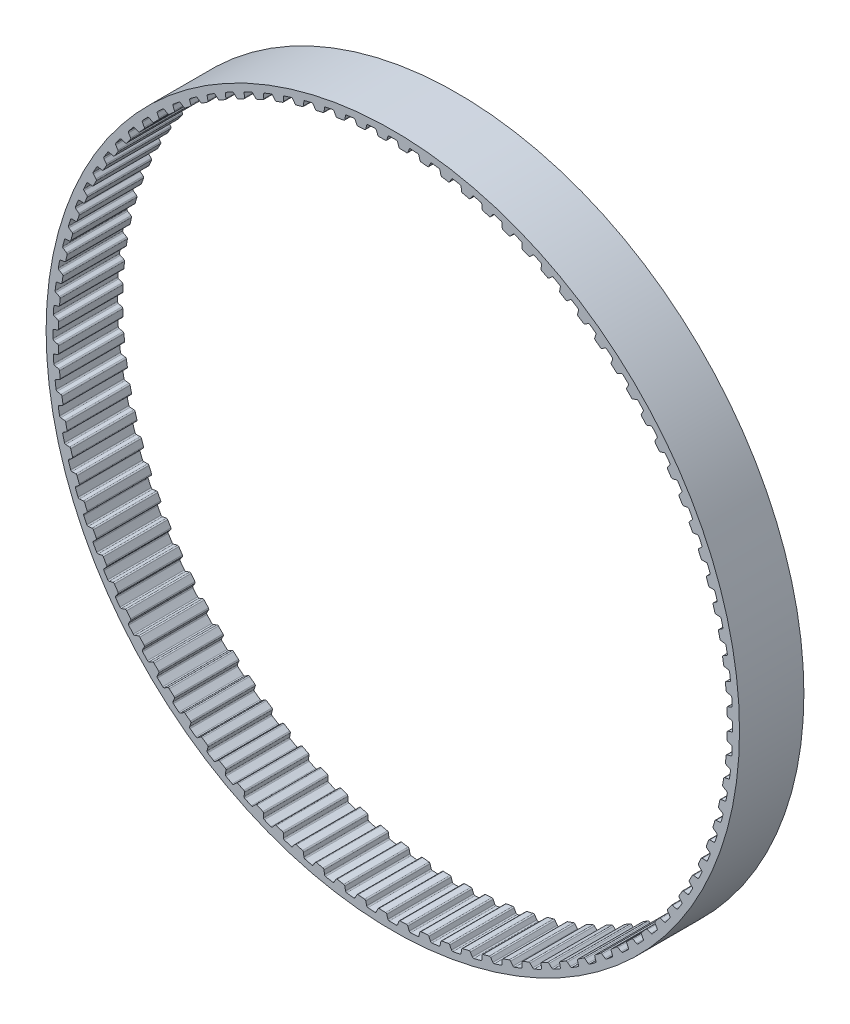
from build123d import *

# Parameters (mm, degrees)
SKETCH4_R           = 32.308480737
SKETCH4_R_2         = 31.165480737
BOSS_EXTRUDE1_DEPTH = 3
CUT_EXTRUDE1_DEPTH  = 3
CIRPATTERN1_COUNT   = 100


with BuildPart() as part:
    # Sketch4 → Boss-Extrude1 (new body, symmetric)
    with BuildSketch(Plane.XY):
        Circle(SKETCH4_R)
        Circle(SKETCH4_R_2, mode=Mode.SUBTRACT)
    extrude(amount=BOSS_EXTRUDE1_DEPTH, both=True)

    # Sketch3 → Cut-Extrude1 (cut, symmetric)
    with BuildSketch(Plane.XY):
        with BuildLine():
            Line((-0.680932012, 31.158041036), (0.680932012, 31.158041036))
            ThreePointArc((0.680932012, 31.158041036), (0.608118055, 31.182955155), (0.563060374, 31.245344184))
            Line((0.563060374, 31.245344184), (0.451580741, 31.584411413))
            ThreePointArc((0.451580741, 31.584411413), (0.405942163, 31.64722814), (0.332266568, 31.67173789))
            ThreePointArc((0.332266568, 31.67173789), (0, 31.673480737), (-0.332266568, 31.67173789))
            ThreePointArc((-0.332266568, 31.67173789), (-0.405942163, 31.64722814), (-0.451580741, 31.584411413))
            Line((-0.451580741, 31.584411413), (-0.563060374, 31.245344184))
            ThreePointArc((-0.563060374, 31.245344184), (-0.608118055, 31.182955155), (-0.680932012, 31.158041036))
        make_face()
    cut_extrude1 = extrude(amount=CUT_EXTRUDE1_DEPTH, both=True, mode=Mode.SUBTRACT)

    # CirPattern1: Cut-Extrude1 ×100 about axis
    cirpattern1_axis = Axis((0, 0, 0), (0, 0, 1))
    for i in range(1, CIRPATTERN1_COUNT):
        add(cut_extrude1.rotate(cirpattern1_axis, i * 360 / CIRPATTERN1_COUNT), mode=Mode.SUBTRACT)


solid = part.part
